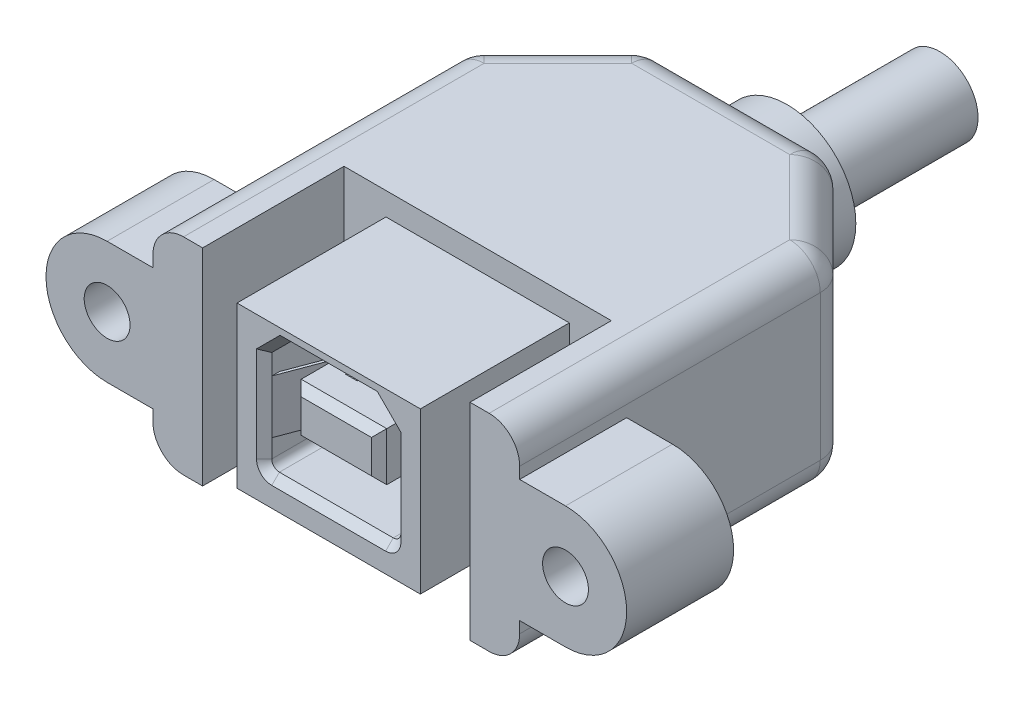
from build123d import *

# Parameters (mm, degrees)
SKETCH1_W                    = 12
SKETCH1_H                    = 10.5
BASE_DEPTH                   = 8.25
CONTACT_OPENING_DEPTH        = 9
CONTACT_OPENING_LEAD_IN_SIZE = 0.5
SKETCH3_W                    = 5.6
SKETCH3_H                    = 3.18
CONTACT_AREA_DEPTH           = 8.5
CONTACT_AREA_LEAD_IN_SIZE    = 0.5
HOLDING_TINES_DEPTH          = 1.75
CONTACT_DEPTH                = 0.375
CONTACT_PATTERN_COUNT        = 2
CONTACT_PATTERN_PITCH        = 2.5
BOSS_EXTRUDE1_DEPTH          = 6.75
CHAMFER1_SIZE                = 6
SKETCH17_R                   = 1.5
CUT_EXTRUDE1_DEPTH           = 34.298836316
CUT_EXTRUDE2_DEPTH           = 34.298836316
FILLET1_R                    = 2
SKETCH20_R                   = 4.5
BOSS_EXTRUDE2_DEPTH          = 3
SKETCH21_R                   = 2.5
BOSS_EXTRUDE3_DEPTH          = 10


with BuildPart() as part:
    # Sketch1 → Base (new, symmetric)
    with BuildSketch(Plane.XY):
        Rectangle(SKETCH1_W, SKETCH1_H)
    extrude(amount=BASE_DEPTH, both=True)

    # Sketch2 → Contact Opening (cut)
    with BuildSketch(Plane.XY.offset(8.25)):
        with BuildLine():
            Line((-2.975, 4.33), (-4.225, 3.08))
            Line((-4.225, 3.08), (-4.225, -2.95))
            ThreePointArc((-4.225, -2.95), (-4.078553391, -3.303553391), (-3.725, -3.45))
            Line((-3.725, -3.45), (3.725, -3.45))
            ThreePointArc((3.725, -3.45), (4.078553391, -3.303553391), (4.225, -2.95))
            Line((4.225, -2.95), (4.225, 3.08))
            Line((4.225, 3.08), (2.975, 4.33))
            Line((2.975, 4.33), (-2.975, 4.33))
        make_face()
    extrude(amount=-CONTACT_OPENING_DEPTH, mode=Mode.SUBTRACT)

    # Contact Opening Lead-in
    contact_opening_lead_in_edges = [part.edges().sort_by_distance(p)[0] for p in [
        (-3.6, 3.705, 8.25),
        (0, 4.33, 8.25),
        (3.6, 3.705, 8.25),
        (4.225, 0.065, 8.25),
        (4.078553391, -3.303553391, 8.25),
        (0, -3.45, 8.25),
        (-4.078553391, -3.303553391, 8.25),
        (-4.225, 0.065, 8.25),
    ]]
    chamfer(contact_opening_lead_in_edges, length=CONTACT_OPENING_LEAD_IN_SIZE)

    # Sketch3 → Contact Area (add)
    with BuildSketch(Plane.XY.offset(-0.75)):
        with Locations((0, 0.44)):
            Rectangle(SKETCH3_W, SKETCH3_H)
    extrude(amount=CONTACT_AREA_DEPTH)

    # Contact Area Lead-in
    contact_area_lead_in_edges = [part.edges().sort_by_distance(p)[0] for p in [
        (0, 2.03, 7.75),
        (2.8, 0.44, 7.75),
        (0, -1.15, 7.75),
        (-2.8, 0.44, 7.75),
    ]]
    chamfer(contact_area_lead_in_edges, length=CONTACT_AREA_LEAD_IN_SIZE)

    # Sketch7 → Holding Tines (add, symmetric)
    with BuildSketch(Plane(origin=(0, 0, 0), x_dir=(1, 0, 0), z_dir=(0, 1, 0))):
        with BuildLine():
            Line((-4.225, -7.75), (-3.215243234, -5.051316752))
            ThreePointArc((-3.215243234, -5.051316752), (-3.027350135, -3.881276433), (-3.307189725, -2.729760924))
            Line((-3.307189725, -2.729760924), (-3.695, -1.9))
            Line((-3.695, -1.9), (-3.853538933, -1.974097279))
            Line((-3.853538933, -1.974097279), (-3.465728658, -2.803858203))
            ThreePointArc((-3.465728658, -2.803858203), (-3.202213044, -3.888201975), (-3.379145712, -4.989989942))
            Line((-3.379145712, -4.989989942), (-4.388902478, -7.688673189))
            Line((-4.388902478, -7.688673189), (-4.225, -7.75))
        make_face()
        with BuildLine():
            Line((4.225, -7.75), (4.388902478, -7.688673189))
            Line((4.388902478, -7.688673189), (3.379145712, -4.989989942))
            ThreePointArc((3.379145712, -4.989989942), (3.202213044, -3.888201975), (3.465728658, -2.803858203))
            Line((3.465728658, -2.803858203), (3.853538933, -1.974097279))
            Line((3.853538933, -1.974097279), (3.695, -1.9))
            Line((3.695, -1.9), (3.307189725, -2.729760924))
            ThreePointArc((3.307189725, -2.729760924), (3.027350135, -3.881276433), (3.215243234, -5.051316752))
            Line((3.215243234, -5.051316752), (4.225, -7.75))
        make_face()
    extrude(amount=HOLDING_TINES_DEPTH, both=True)

    # Sketch8 → Contact (add, symmetric)
    with BuildSketch(Plane(origin=(-1.25, 0, 0), x_dir=(0, 0, -1), z_dir=(1, 0, 0))):
        with BuildLine():
            Line((0.75, 2.03), (-2.695251124, 2.678262825))
            ThreePointArc((-2.695251124, 2.678262825), (-3.57053143, 2.712827451), (-4.418484282, 2.493086043))
            Line((-4.418484282, 2.493086043), (-5.75, 1.93))
            Line((-5.75, 1.93), (-5.681838417, 1.768819981))
            Line((-5.681838417, 1.768819981), (-4.350322699, 2.331906024))
            ThreePointArc((-4.350322699, 2.331906024), (-3.551833763, 2.538829183), (-2.727611475, 2.506280827))
            Line((-2.727611475, 2.506280827), (0.717639649, 1.858018002))
            Line((0.717639649, 1.858018002), (0.75, 2.03))
        make_face()
        with BuildLine():
            Line((-5.681838417, -0.888819981), (-5.75, -1.05))
            Line((-5.75, -1.05), (-4.418484282, -1.613086043))
            ThreePointArc((-4.418484282, -1.613086043), (-3.57053143, -1.832827451), (-2.695251124, -1.798262825))
            Line((-2.695251124, -1.798262825), (0.75, -1.15))
            Line((0.75, -1.15), (0.717639649, -0.978018002))
            Line((0.717639649, -0.978018002), (-2.727611475, -1.626280827))
            ThreePointArc((-2.727611475, -1.626280827), (-3.551833763, -1.658829183), (-4.350322699, -1.451906024))
            Line((-4.350322699, -1.451906024), (-5.681838417, -0.888819981))
        make_face()
    contact = extrude(amount=CONTACT_DEPTH, both=True)

    # Contact Pattern: Contact ×2
    with Locations(*[(i * CONTACT_PATTERN_PITCH, 0, 0) for i in range(1, CONTACT_PATTERN_COUNT)]):
        add(contact)


with BuildPart() as body_2:
    # Sketch16 → Boss-Extrude1 (new, symmetric)
    with BuildSketch(Plane(origin=(0, 0, 0), x_dir=(1, 0, 0), z_dir=(0, 1, 0))):
        Polygon((-8.75, 1.5), (0, 1.5), (0, 18.75), (-12, 18.75), (-12, -0.75), (-19, -0.75), (-19, -7.75), (-8.75, -7.75), align=None)
    extrude(amount=BOSS_EXTRUDE1_DEPTH, both=True)

    # Chamfer1
    chamfer1_edges = [body_2.edges().sort_by_distance(p)[0] for p in [
        (-12, 0, -18.75),
    ]]
    chamfer(chamfer1_edges, length=CHAMFER1_SIZE)

    # Sketch17 → Cut-Extrude1 (cut, through all)
    with BuildSketch(Plane.XY.offset(7.75)):
        with Locations((-15, 0)):
            Circle(SKETCH17_R)
    extrude(amount=-CUT_EXTRUDE1_DEPTH, mode=Mode.SUBTRACT)

    # Sketch18 → Cut-Extrude2 (cut, through all)
    with BuildSketch(Plane.XY.offset(7.75)):
        with BuildLine():
            ThreePointArc((-19, 0), (-17.828427125, 2.828427125), (-15, 4))
            Line((-15, 4), (-12, 4))
            Line((-12, 4), (-12, 6.75))
            Line((-12, 6.75), (-19, 6.75))
            Line((-19, 6.75), (-19, 0))
        make_face()
        with BuildLine():
            ThreePointArc((-15, -4), (-17.828427125, -2.828427125), (-19, 0))
            Line((-19, 0), (-19, -6.75))
            Line((-19, -6.75), (-12, -6.75))
            Line((-12, -6.75), (-12, -4))
            Line((-12, -4), (-15, -4))
        make_face()
    extrude(amount=-CUT_EXTRUDE2_DEPTH, mode=Mode.SUBTRACT)

    # Fillet1
    fillet1_edges = [body_2.edges().sort_by_distance(p)[0] for p in [
        (-12, 0, -12.75),
        (-6, 0, -18.75),
        (-3, 6.75, -18.75),
        (-3, -6.75, -18.75),
        (-12, -6.75, -2.5),
        (-9, -6.75, -15.75),
        (-12, 6.75, -2.5),
        (-9, 6.75, -15.75),
    ]]
    fillet(fillet1_edges, radius=FILLET1_R)

    # Mirror1: body 2 across plane


with BuildPart() as body_2_1:
    add(body_2.part)
    add(body_2.part.mirror(Plane(origin=(0, 6.75, -18.75), x_dir=(0, 0, 1), z_dir=(-1, 0, 0))))

    # Sketch20 → Boss-Extrude2 (add)
    with BuildSketch(Plane(origin=(0, 0, -18.75), x_dir=(-1, 0, 0), z_dir=(0, 0, -1))):
        Circle(SKETCH20_R)
    extrude(amount=BOSS_EXTRUDE2_DEPTH)

    # Sketch21 → Boss-Extrude3 (add)
    with BuildSketch(Plane(origin=(0, 0, -21.75), x_dir=(-1, 0, 0), z_dir=(0, 0, -1))):
        Circle(SKETCH21_R)
    extrude(amount=BOSS_EXTRUDE3_DEPTH)


with BuildPart() as part_1:
    add(part.part)

    # Combine1: union body 2
    add(body_2_1.part)


solid = part_1.part
